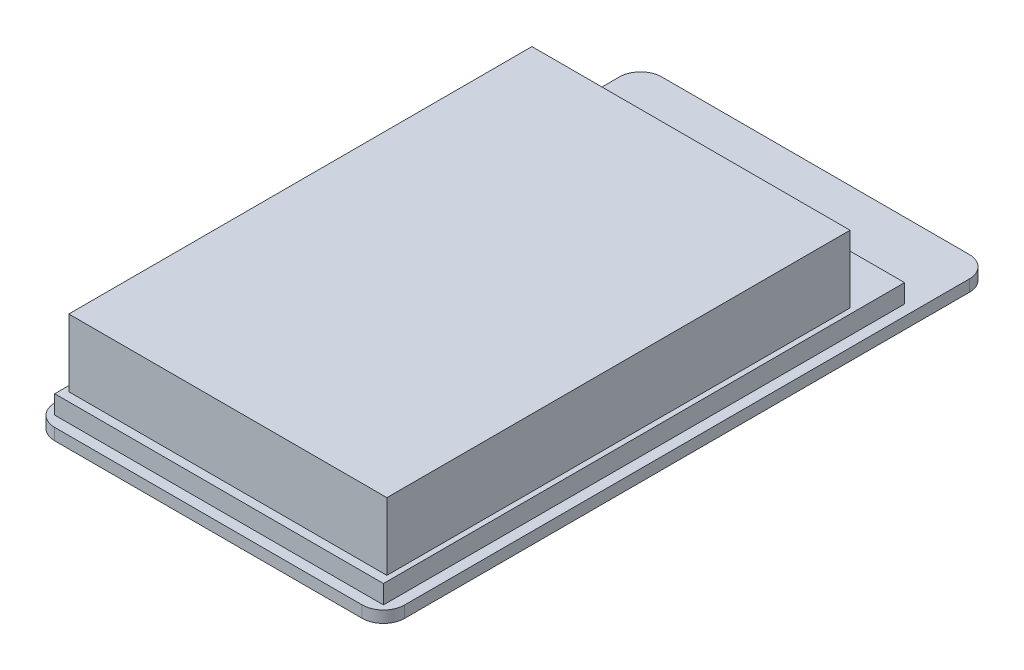
from build123d import *

# Parameters (mm, degrees)
SKETCH_1_W      = 66
SKETCH_1_H      = 114.5
EXTRUDE_1_DEPTH = 2.2
FILLET_1_R      = 4
SKETCH_2_W      = 62
SKETCH_2_H      = 98.3
EXTRUDE_2_DEPTH = 3.5
SKETCH_3_W      = 60
SKETCH_3_H      = 87.364717042
EXTRUDE_3_DEPTH = 12.7


with BuildPart() as part:
    # 스케치1 → 보스-돌출1 (new body)
    with BuildSketch(Plane(origin=(0, 0, 0), x_dir=(1, 0, 0), z_dir=(0, 1, 0))):
        Rectangle(SKETCH_1_W, SKETCH_1_H)
    extrude(amount=EXTRUDE_1_DEPTH)

    # 필렛1
    fillet_1_edges = [part.edges().sort_by_distance(p)[0] for p in [
        (-33, 1.1, -57.25),
        (33, 1.1, -57.25),
        (33, 1.1, 57.25),
        (-33, 1.1, 57.25),
    ]]
    fillet(fillet_1_edges, radius=FILLET_1_R)

    # 스케치2 → 보스-돌출2 (add)
    with BuildSketch(Plane(origin=(0, 2.2, 0), x_dir=(1, 0, 0), z_dir=(0, 1, 0))):
        with Locations((0, -6.1)):
            Rectangle(SKETCH_2_W, SKETCH_2_H)
    extrude(amount=EXTRUDE_2_DEPTH)

    # 스케치3 → 보스-돌출3 (add)
    with BuildSketch(Plane(origin=(0, 5.7, 0), x_dir=(1, 0, 0), z_dir=(0, 1, 0))):
        with Locations((0, -9.917641479)):
            Rectangle(SKETCH_3_W, SKETCH_3_H)
    extrude(amount=EXTRUDE_3_DEPTH)


solid = part.part
